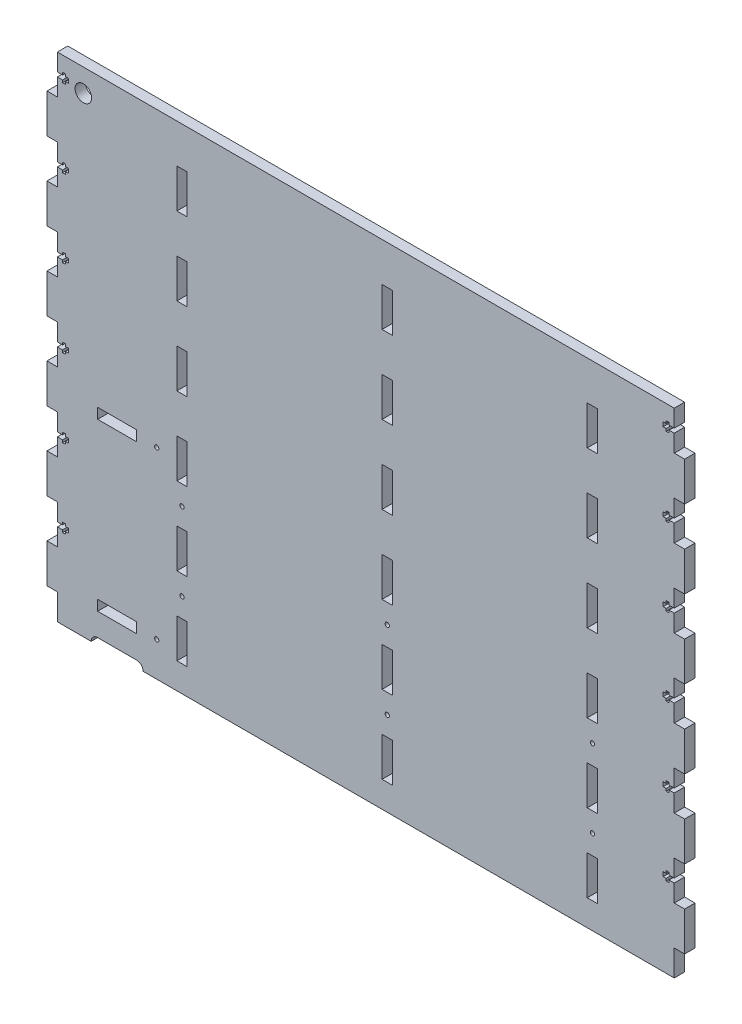
from build123d import *

# Parameters (mm, degrees)
SKETCH1_W           = 475
SKETCH1_H           = 380
SKETCH1_R           = 6.35
SKETCH1_R_2         = 1.65
SKETCH1_W_2         = 8
SKETCH1_H_2         = 30
SKETCH1_W_3         = 30
SKETCH1_H_3         = 8
BOSS_EXTRUDE1_DEPTH = 8
SKETCH2_W           = 8
SKETCH2_H           = 30
BOSS_EXTRUDE2_DEPTH = 8
CUT_EXTRUDE2_DEPTH  = 9


with BuildPart() as part:
    # Sketch1 → Boss-Extrude1 (new body)
    with BuildSketch(Plane.XY):
        with Locations((237.5, 190)):
            Rectangle(SKETCH1_W, SKETCH1_H)
        with Locations((20, 362.5)):
            Circle(SKETCH1_R, mode=Mode.SUBTRACT)
        with Locations((76.5, 154.566938385)):
            Circle(SKETCH1_R_2, mode=Mode.SUBTRACT)
        with Locations((76.5, 26.566938385)):
            Circle(SKETCH1_R_2, mode=Mode.SUBTRACT)
        with Locations((96, 125)):
            Circle(SKETCH1_R_2, mode=Mode.SUBTRACT)
        with Locations((254, 125)):
            Circle(SKETCH1_R_2, mode=Mode.SUBTRACT)
        with Locations((412, 125)):
            Circle(SKETCH1_R_2, mode=Mode.SUBTRACT)
        with Locations((96, 65)):
            Circle(SKETCH1_R_2, mode=Mode.SUBTRACT)
        with Locations((254, 65)):
            Circle(SKETCH1_R_2, mode=Mode.SUBTRACT)
        with Locations((412, 65)):
            Circle(SKETCH1_R_2, mode=Mode.SUBTRACT)
        with Locations((254, 335)):
            Rectangle(SKETCH1_W_2, SKETCH1_H_2, mode=Mode.SUBTRACT)
        with Locations((46, 154.566938385)):
            Rectangle(SKETCH1_W_3, SKETCH1_H_3, mode=Mode.SUBTRACT)
        with Locations((46, 26.566938385)):
            Rectangle(SKETCH1_W_3, SKETCH1_H_3, mode=Mode.SUBTRACT)
        with Locations((96, 335)):
            Rectangle(SKETCH1_W_2, SKETCH1_H_2, mode=Mode.SUBTRACT)
        with Locations((412, 335)):
            Rectangle(SKETCH1_W_2, SKETCH1_H_2, mode=Mode.SUBTRACT)
        with Locations((96, 275)):
            Rectangle(SKETCH1_W_2, SKETCH1_H_2, mode=Mode.SUBTRACT)
        with Locations((254, 275)):
            Rectangle(SKETCH1_W_2, SKETCH1_H_2, mode=Mode.SUBTRACT)
        with Locations((412, 275)):
            Rectangle(SKETCH1_W_2, SKETCH1_H_2, mode=Mode.SUBTRACT)
        with Locations((96, 215)):
            Rectangle(SKETCH1_W_2, SKETCH1_H_2, mode=Mode.SUBTRACT)
        with Locations((254, 215)):
            Rectangle(SKETCH1_W_2, SKETCH1_H_2, mode=Mode.SUBTRACT)
        with Locations((412, 215)):
            Rectangle(SKETCH1_W_2, SKETCH1_H_2, mode=Mode.SUBTRACT)
        with Locations((96, 155)):
            Rectangle(SKETCH1_W_2, SKETCH1_H_2, mode=Mode.SUBTRACT)
        with Locations((254, 155)):
            Rectangle(SKETCH1_W_2, SKETCH1_H_2, mode=Mode.SUBTRACT)
        with Locations((412, 155)):
            Rectangle(SKETCH1_W_2, SKETCH1_H_2, mode=Mode.SUBTRACT)
        with Locations((96, 95)):
            Rectangle(SKETCH1_W_2, SKETCH1_H_2, mode=Mode.SUBTRACT)
        with Locations((254, 95)):
            Rectangle(SKETCH1_W_2, SKETCH1_H_2, mode=Mode.SUBTRACT)
        with Locations((412, 95)):
            Rectangle(SKETCH1_W_2, SKETCH1_H_2, mode=Mode.SUBTRACT)
        with Locations((96, 35)):
            Rectangle(SKETCH1_W_2, SKETCH1_H_2, mode=Mode.SUBTRACT)
        with Locations((254, 35)):
            Rectangle(SKETCH1_W_2, SKETCH1_H_2, mode=Mode.SUBTRACT)
        with Locations((412, 35)):
            Rectangle(SKETCH1_W_2, SKETCH1_H_2, mode=Mode.SUBTRACT)
    extrude(amount=BOSS_EXTRUDE1_DEPTH)

    # Sketch2 → Boss-Extrude2 (add)
    with BuildSketch(Plane.XY.offset(8)):
        with Locations((479, 335)):
            Rectangle(SKETCH2_W, SKETCH2_H)
        with Locations((-4, 335)):
            Rectangle(SKETCH2_W, SKETCH2_H)
        with Locations((-4, 275)):
            Rectangle(SKETCH2_W, SKETCH2_H)
        with Locations((479, 275)):
            Rectangle(SKETCH2_W, SKETCH2_H)
        with Locations((-4, 215)):
            Rectangle(SKETCH2_W, SKETCH2_H)
        with Locations((479, 215)):
            Rectangle(SKETCH2_W, SKETCH2_H)
        with Locations((-4, 155)):
            Rectangle(SKETCH2_W, SKETCH2_H)
        with Locations((479, 155)):
            Rectangle(SKETCH2_W, SKETCH2_H)
        with Locations((-4, 95)):
            Rectangle(SKETCH2_W, SKETCH2_H)
        with Locations((479, 95)):
            Rectangle(SKETCH2_W, SKETCH2_H)
        with Locations((-4, 35)):
            Rectangle(SKETCH2_W, SKETCH2_H)
        with Locations((479, 35)):
            Rectangle(SKETCH2_W, SKETCH2_H)
    extrude(amount=-BOSS_EXTRUDE2_DEPTH)

    # Sketch4 → Cut-Extrude2 (cut, through all)
    with BuildSketch(Plane.XY.offset(8)):
        Polygon((475, 366.65), (471, 366.65), (471, 368.5), (468.8, 368.5), (468.8, 366.65), (466.5, 366.65), (466.5, 363.35), (468.8, 363.35), (468.8, 361.5), (471, 361.5), (471, 363.35), (475, 363.35), align=None)
        Polygon((0, 66.65), (0, 63.35), (4, 63.35), (4, 61.5), (6.2, 61.5), (6.2, 63.35), (8.5, 63.35), (8.5, 66.65), (6.2, 66.65), (6.2, 68.5), (4, 68.5), (4, 66.65), align=None)
        Polygon((0, 126.65), (0, 123.35), (4, 123.35), (4, 121.5), (6.2, 121.5), (6.2, 123.35), (8.5, 123.35), (8.5, 126.65), (6.2, 126.65), (6.2, 128.5), (4, 128.5), (4, 126.65), align=None)
        Polygon((0, 186.65), (0, 183.35), (4, 183.35), (4, 181.5), (6.2, 181.5), (6.2, 183.35), (8.5, 183.35), (8.5, 186.65), (6.2, 186.65), (6.2, 188.5), (4, 188.5), (4, 186.65), align=None)
        Polygon((0, 246.65), (0, 243.35), (4, 243.35), (4, 241.5), (6.2, 241.5), (6.2, 243.35), (8.5, 243.35), (8.5, 246.65), (6.2, 246.65), (6.2, 248.5), (4, 248.5), (4, 246.65), align=None)
        Polygon((0, 306.65), (0, 303.35), (4, 303.35), (4, 301.5), (6.2, 301.5), (6.2, 303.35), (8.5, 303.35), (8.5, 306.65), (6.2, 306.65), (6.2, 308.5), (4, 308.5), (4, 306.65), align=None)
        Polygon((0, 366.65), (0, 363.35), (4, 363.35), (4, 361.5), (6.2, 361.5), (6.2, 363.35), (8.5, 363.35), (8.5, 366.65), (6.2, 366.65), (6.2, 368.5), (4, 368.5), (4, 366.65), align=None)
        with BuildLine():
            Line((31, 5), (61, 5))
            ThreePointArc((61, 5), (66, 0), (61, -5))
            Line((61, -5), (31, -5))
            ThreePointArc((31, -5), (26, 0), (31, 5))
        make_face()
        Polygon((475, 306.65), (471, 306.65), (471, 308.5), (468.8, 308.5), (468.8, 306.65), (466.5, 306.65), (466.5, 303.35), (468.8, 303.35), (468.8, 301.5), (471, 301.5), (471, 303.35), (475, 303.35), align=None)
        Polygon((475, 246.65), (471, 246.65), (471, 248.5), (468.8, 248.5), (468.8, 246.65), (466.5, 246.65), (466.5, 243.35), (468.8, 243.35), (468.8, 241.5), (471, 241.5), (471, 243.35), (475, 243.35), align=None)
        Polygon((475, 186.65), (471, 186.65), (471, 188.5), (468.8, 188.5), (468.8, 186.65), (466.5, 186.65), (466.5, 183.35), (468.8, 183.35), (468.8, 181.5), (471, 181.5), (471, 183.35), (475, 183.35), align=None)
        Polygon((475, 126.65), (471, 126.65), (471, 128.5), (468.8, 128.5), (468.8, 126.65), (466.5, 126.65), (466.5, 123.35), (468.8, 123.35), (468.8, 121.5), (471, 121.5), (471, 123.35), (475, 123.35), align=None)
        Polygon((475, 66.65), (471, 66.65), (471, 68.5), (468.8, 68.5), (468.8, 66.65), (466.5, 66.65), (466.5, 63.35), (468.8, 63.35), (468.8, 61.5), (471, 61.5), (471, 63.35), (475, 63.35), align=None)
    extrude(amount=-CUT_EXTRUDE2_DEPTH, mode=Mode.SUBTRACT)


solid = part.part
